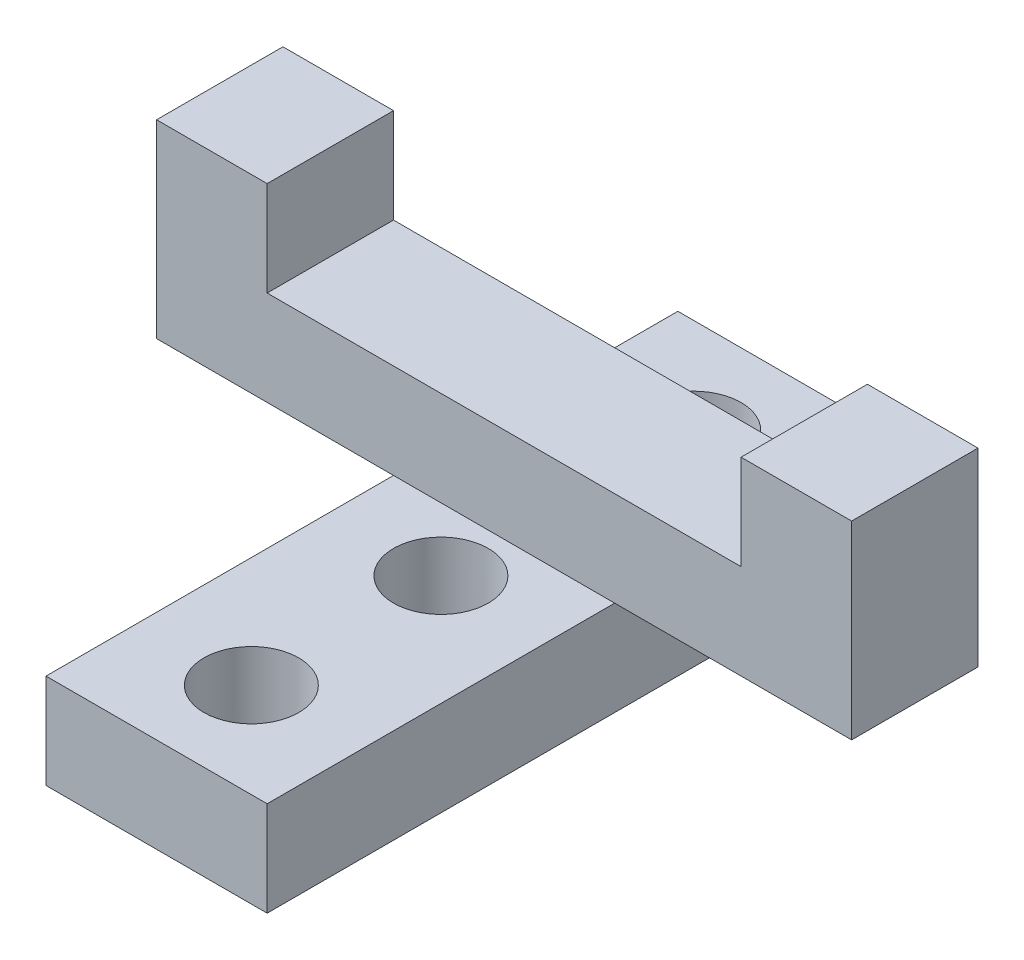
from build123d import *

# Parameters (mm, degrees)
SKETCH2_W                    = 7
SKETCH2_H                    = 20
EXTRUDE2_DEPTH               = 3
F_3_0_3_DIAMETER_HOLE1_D     = 3
F_3_0_3_DIAMETER_HOLE1_DEPTH = 10
F_3_0_3_DIAMETER_HOLE1_TIP   = 0.901290929
SKETCH6_W                    = 7
SKETCH6_H                    = 4
EXTRUDE3_DEPTH               = 6
SKETCH7_W                    = 4
SKETCH7_H                    = 6
EXTRUDE4_DEPTH               = 7.5
SKETCH8_W                    = 4
SKETCH8_H                    = 6
EXTRUDE5_DEPTH               = 7.5
SKETCH10_W                   = 15
SKETCH10_H                   = 4
EXTRUDE6_DEPTH               = 3


with BuildPart() as part:
    # Sketch2 → Extrude2 (new body)
    with BuildSketch(Plane(origin=(0, 0, 0), x_dir=(1, 0, 0), z_dir=(0, 1, 0))):
        Rectangle(SKETCH2_W, SKETCH2_H)
    extrude(amount=EXTRUDE2_DEPTH)

    # Ø3.0 (3) Diameter Hole1
    with Locations(Plane(origin=(0, 3, 7), x_dir=(0, 0, 1), z_dir=(0, 1, 0))):
        with Locations((0, 0), (-6, 0), (-14, 0)):
            Hole(F_3_0_3_DIAMETER_HOLE1_D / 2, depth=F_3_0_3_DIAMETER_HOLE1_DEPTH)
            with Locations((0, 0, -(F_3_0_3_DIAMETER_HOLE1_DEPTH + F_3_0_3_DIAMETER_HOLE1_TIP / 2))):  # 118° drill point
                Cone(0, F_3_0_3_DIAMETER_HOLE1_D / 2, F_3_0_3_DIAMETER_HOLE1_TIP, mode=Mode.SUBTRACT)

    # Sketch6 → Extrude3 (add)
    with BuildSketch(Plane(origin=(0, 3, 0), x_dir=(1, 0, 0), z_dir=(0, 1, 0))):
        with Locations((0, 3)):
            Rectangle(SKETCH6_W, SKETCH6_H)
    extrude(amount=EXTRUDE3_DEPTH)

    # Sketch7 → Extrude4 (add)
    with BuildSketch(Plane(origin=(3.5, 0, 0), x_dir=(0, 0, -1), z_dir=(1, 0, 0))):
        with Locations((3, 6)):
            Rectangle(SKETCH7_W, SKETCH7_H)
    extrude(amount=EXTRUDE4_DEPTH)

    # Sketch8 → Extrude5 (add)
    with BuildSketch(Plane.ZY.offset(3.5)):
        with Locations((-3, 6)):
            Rectangle(SKETCH8_W, SKETCH8_H)
    extrude(amount=EXTRUDE5_DEPTH)

    # Sketch10 → Extrude6 (cut)
    with BuildSketch(Plane(origin=(0, 9, 0), x_dir=(-1, 0, 0), z_dir=(0, 1, 0))):
        with Locations((0, -3)):
            Rectangle(SKETCH10_W, SKETCH10_H)
    extrude(amount=-EXTRUDE6_DEPTH, mode=Mode.SUBTRACT)


solid = part.part
